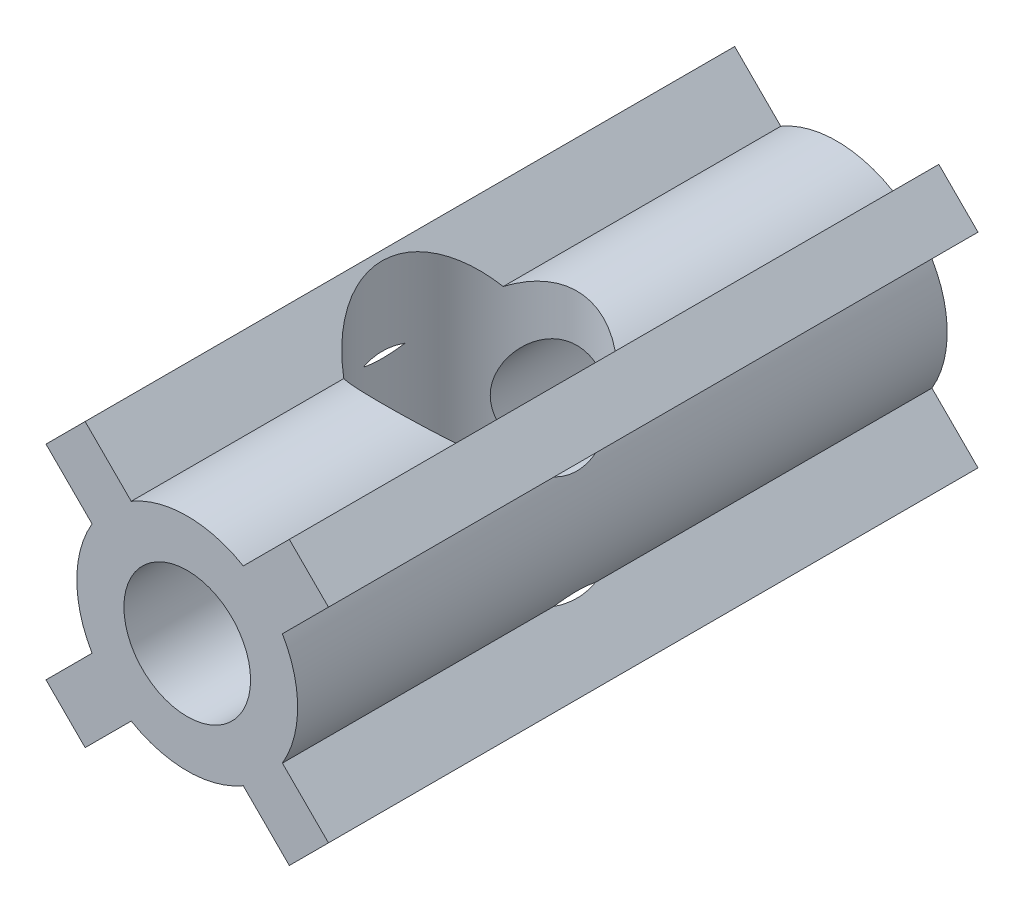
from build123d import *

# Parameters (mm, degrees)
SKETCH1_R               = 1.95
BOSS_EXTRUDE1_DEPTH     = 20
CUT_EXTRUDE1_DEPTH      = 20
CUT_EXTRUDE1_DEPTH_BACK = 20
SKETCH2_R               = 3


with BuildPart() as part:
    # Sketch1 → Boss-Extrude1 (new body)
    with BuildSketch(Plane.XY):
        with BuildLine():
            Line((3.143089642, 4.348706704), (4.348706704, 3.143089642))
            Line((4.348706704, 3.143089642), (2.930172249, 1.724555187))
            ThreePointArc((2.930172249, 1.724555187), (3.4, 0), (2.930172249, -1.724555187))
            Line((2.930172249, -1.724555187), (4.348706704, -3.143089642))
            Line((4.348706704, -3.143089642), (3.143089642, -4.348706704))
            Line((3.143089642, -4.348706704), (1.724555187, -2.930172249))
            ThreePointArc((1.724555187, -2.930172249), (0, -3.4), (-1.724555187, -2.930172249))
            Line((-1.724555187, -2.930172249), (-3.143089642, -4.348706704))
            Line((-3.143089642, -4.348706704), (-4.348706704, -3.143089642))
            Line((-4.348706704, -3.143089642), (-2.930172249, -1.724555187))
            ThreePointArc((-2.930172249, -1.724555187), (-3.4, 0), (-2.930172249, 1.724555187))
            Line((-2.930172249, 1.724555187), (-4.348706704, 3.143089642))
            Line((-4.348706704, 3.143089642), (-3.143089642, 4.348706704))
            Line((-3.143089642, 4.348706704), (-1.724555187, 2.930172249))
            ThreePointArc((-1.724555187, 2.930172249), (0, 3.4), (1.724555187, 2.930172249))
            Line((1.724555187, 2.930172249), (3.143089642, 4.348706704))
        make_face()
        Circle(SKETCH1_R, mode=Mode.SUBTRACT)
    extrude(amount=BOSS_EXTRUDE1_DEPTH)

    # Sketch2 → Cut-Extrude1 (cut, two sides: drawn at the far end of the back side and taken through both)
    with BuildSketch(Plane(origin=(0, 0, 0), x_dir=(1, 0, 0), z_dir=(0, 1, 0)).offset(-CUT_EXTRUDE1_DEPTH_BACK)):
        with Locations((0, -11)):
            Circle(SKETCH2_R)
    extrude(amount=CUT_EXTRUDE1_DEPTH + CUT_EXTRUDE1_DEPTH_BACK, mode=Mode.SUBTRACT)


solid = part.part
